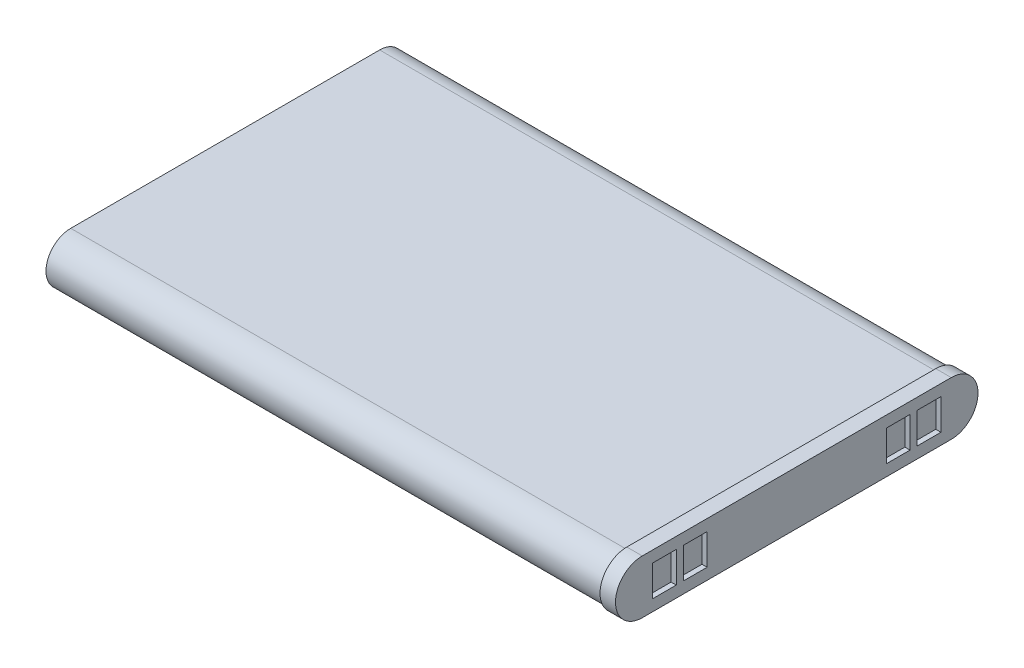
from build123d import *

# Parameters (mm, degrees)
BOSS_EXTRUDE1_DEPTH = 54
BOSS_EXTRUDE2_DEPTH = 1.5
SKETCH3_W           = 2.3
SKETCH3_H           = 3
CUT_EXTRUDE1_DEPTH  = 0.5


with BuildPart() as part:
    # Sketch1 → Boss-Extrude1 (new body)
    with BuildSketch(Plane(origin=(0, 0, 0), x_dir=(0, 0, -1), z_dir=(1, 0, 0))):
        with BuildLine():
            Line((-15, 2.4), (15, 2.4))
            ThreePointArc((15, 2.4), (17.4, 0), (15, -2.4))
            Line((15, -2.4), (-15, -2.4))
            ThreePointArc((-15, -2.4), (-17.4, 0), (-15, 2.4))
        make_face()
    extrude(amount=BOSS_EXTRUDE1_DEPTH)

    # Sketch2 → Boss-Extrude2 (add)
    with BuildSketch(Plane(origin=(54, 0, 0), x_dir=(0, 0, -1), z_dir=(1, 0, 0))):
        with BuildLine():
            Line((-15, -2.6), (15, -2.6))
            ThreePointArc((15, -2.6), (17.6, 0), (15, 2.6))
            Line((15, 2.6), (-15, 2.6))
            ThreePointArc((-15, 2.6), (-17.6, 0), (-15, -2.6))
        make_face()
    extrude(amount=BOSS_EXTRUDE2_DEPTH)

    # Sketch3 → Cut-Extrude1 (cut)
    with BuildSketch(Plane(origin=(55.5, 0, 0), x_dir=(0, 0, -1), z_dir=(1, 0, 0))):
        with Locations((-12.85, 0)):
            Rectangle(SKETCH3_W, SKETCH3_H)
        with Locations((-9.85, 0)):
            Rectangle(SKETCH3_W, SKETCH3_H)
        with Locations((9.85, 0)):
            Rectangle(SKETCH3_W, SKETCH3_H)
        with Locations((12.85, 0)):
            Rectangle(SKETCH3_W, SKETCH3_H)
    extrude(amount=-CUT_EXTRUDE1_DEPTH, mode=Mode.SUBTRACT)


solid = part.part
